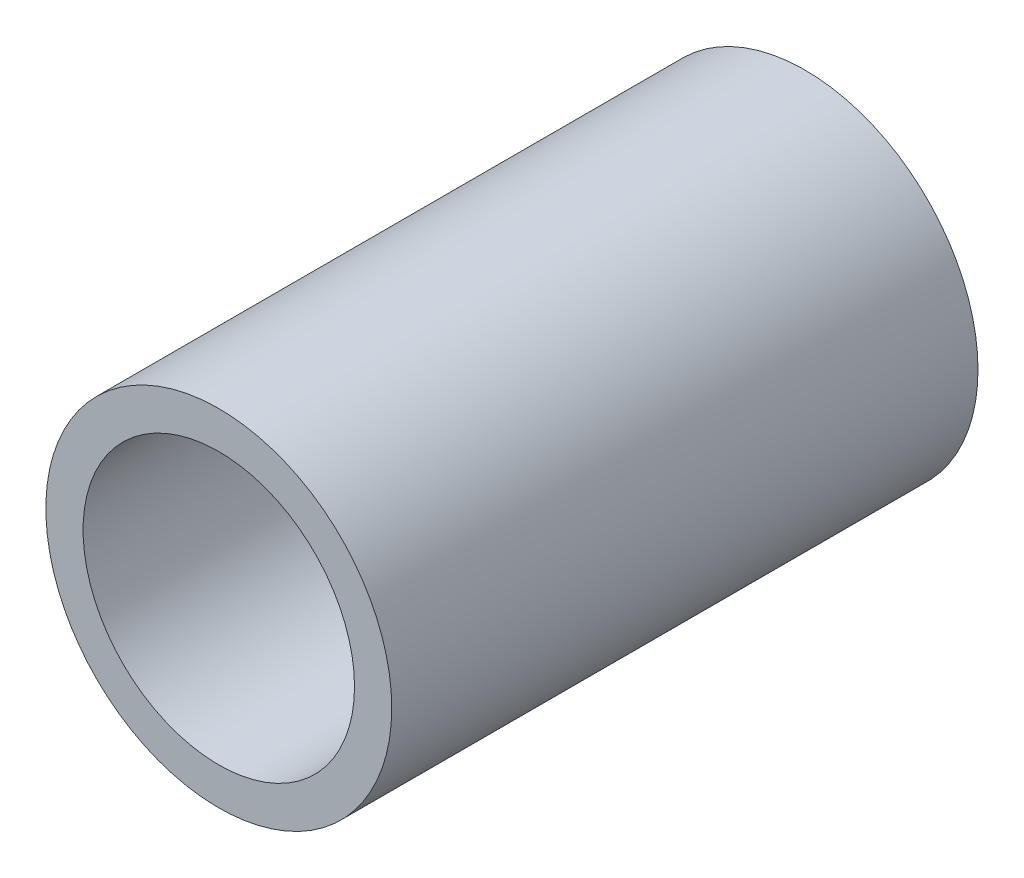
from build123d import *

# Parameters (mm, degrees)
SKETCH3_R                = 13.335
SKETCH3_R_2              = 10.4648
BOSS_EXTRUDE1_DEPTH      = 762
BOSS_EXTRUDE1_DEPTH_BACK = 762
SKETCH4_R                = 13.335
CUT_EXTRUDE2_DEPTH       = 1478.7969


with BuildPart() as part:
    # Sketch3 → Boss-Extrude1 (new body, two sides)
    with BuildSketch(Plane.XY) as boss_extrude1_sk:
        Circle(SKETCH3_R)
        Circle(SKETCH3_R_2, mode=Mode.SUBTRACT)
    extrude(amount=BOSS_EXTRUDE1_DEPTH)
    extrude(boss_extrude1_sk.sketch, amount=-BOSS_EXTRUDE1_DEPTH_BACK)

    # Sketch4 → Cut-Extrude2 (cut)
    with BuildSketch(Plane.XY.offset(762)):
        Circle(SKETCH4_R)
    extrude(amount=-CUT_EXTRUDE2_DEPTH, mode=Mode.SUBTRACT)


solid = part.part
